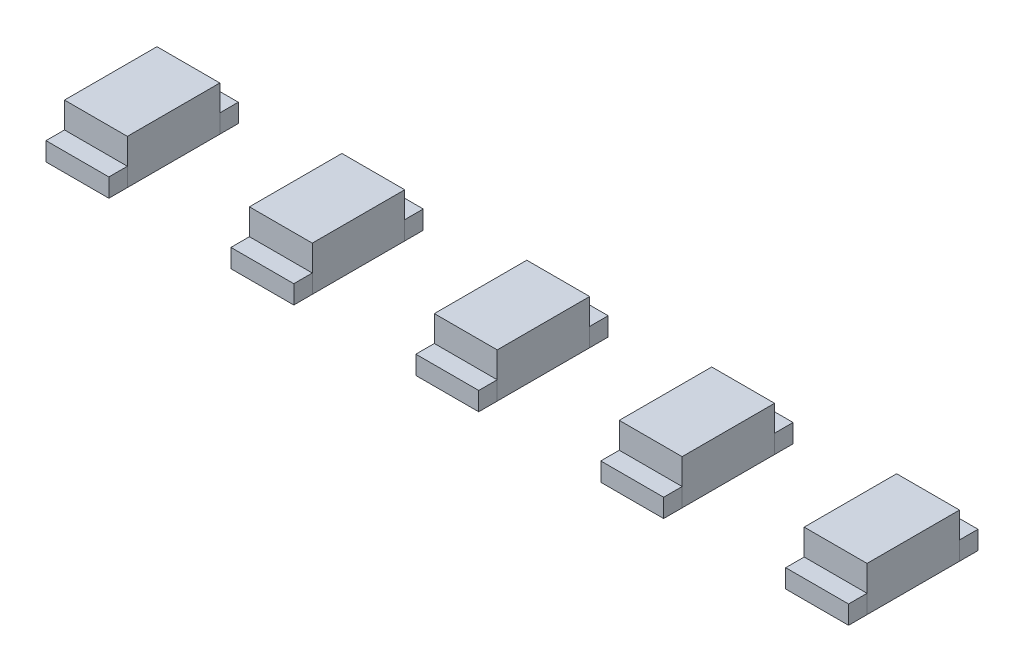
from build123d import *

# Parameters (mm, degrees)
SKETCH1_W             = 0.85
SKETCH1_H             = 1.25
BOSS_EXTRUDE1_DEPTH   = 0.6
BOSS_EXTRUDE1_2_DEPTH = 0.6
BOSS_EXTRUDE1_3_DEPTH = 0.6
BOSS_EXTRUDE1_4_DEPTH = 0.6
BOSS_EXTRUDE1_5_DEPTH = 0.6
SKETCH2_W             = 0.85
SKETCH2_H             = 0.25
BOSS_EXTRUDE2_DEPTH   = 0.25


with BuildPart() as part:
    # Sketch1 → Boss-Extrude1 (new body)
    with BuildSketch(Plane(origin=(0, 0, 0), x_dir=(1, 0, 0), z_dir=(0, 1, 0))):
        with Locations((-5, 0)):
            Rectangle(SKETCH1_W, SKETCH1_H)
    extrude(amount=BOSS_EXTRUDE1_DEPTH)



with BuildPart() as body_2:
    # Sketch1 → Boss-Extrude1 2 (new body)
    with BuildSketch(Plane(origin=(0, 0, 0), x_dir=(1, 0, 0), z_dir=(0, 1, 0))):
        with Locations((5, 0)):
            Rectangle(SKETCH1_W, SKETCH1_H)
    extrude(amount=BOSS_EXTRUDE1_2_DEPTH)


with BuildPart() as body_3:
    # Sketch1 → Boss-Extrude1 3 (new body)
    with BuildSketch(Plane(origin=(0, 0, 0), x_dir=(1, 0, 0), z_dir=(0, 1, 0))):
        with Locations((-2.5, 0)):
            Rectangle(SKETCH1_W, SKETCH1_H)
    extrude(amount=BOSS_EXTRUDE1_3_DEPTH)


with BuildPart() as body_4:
    # Sketch1 → Boss-Extrude1 4 (new body)
    with BuildSketch(Plane(origin=(0, 0, 0), x_dir=(1, 0, 0), z_dir=(0, 1, 0))):
        Rectangle(SKETCH1_W, SKETCH1_H)
    extrude(amount=BOSS_EXTRUDE1_4_DEPTH)


with BuildPart() as body_5:
    # Sketch1 → Boss-Extrude1 5 (new body)
    with BuildSketch(Plane(origin=(0, 0, 0), x_dir=(1, 0, 0), z_dir=(0, 1, 0))):
        with Locations((2.5, 0)):
            Rectangle(SKETCH1_W, SKETCH1_H)
    extrude(amount=BOSS_EXTRUDE1_5_DEPTH)


with BuildPart() as part_1:
    add(part.part)

    add(body_2.part)  # Boss-Extrude2 merges body 2

    add(body_3.part)  # Boss-Extrude2 merges body 3

    add(body_4.part)  # Boss-Extrude2 merges body 4

    add(body_5.part)  # Boss-Extrude2 merges body 5
    # Sketch2 → Boss-Extrude2 (add)
    with BuildSketch(Plane(origin=(0, 0, 0), x_dir=(1, 0, 0), z_dir=(0, 1, 0))):
        with Locations((-5, 0.75)):
            Rectangle(SKETCH2_W, SKETCH2_H)
        with Locations((-2.5, 0.75)):
            Rectangle(SKETCH2_W, SKETCH2_H)
        with Locations((0, 0.75)):
            Rectangle(SKETCH2_W, SKETCH2_H)
        with Locations((2.5, 0.75)):
            Rectangle(SKETCH2_W, SKETCH2_H)
        with Locations((5, 0.75)):
            Rectangle(SKETCH2_W, SKETCH2_H)
        with Locations((5, -0.75)):
            Rectangle(SKETCH2_W, SKETCH2_H)
        with Locations((2.5, -0.75)):
            Rectangle(SKETCH2_W, SKETCH2_H)
        with Locations((0, -0.75)):
            Rectangle(SKETCH2_W, SKETCH2_H)
        with Locations((-2.5, -0.75)):
            Rectangle(SKETCH2_W, SKETCH2_H)
        with Locations((-5, -0.75)):
            Rectangle(SKETCH2_W, SKETCH2_H)
    extrude(amount=BOSS_EXTRUDE2_DEPTH)


solid = part_1.part
